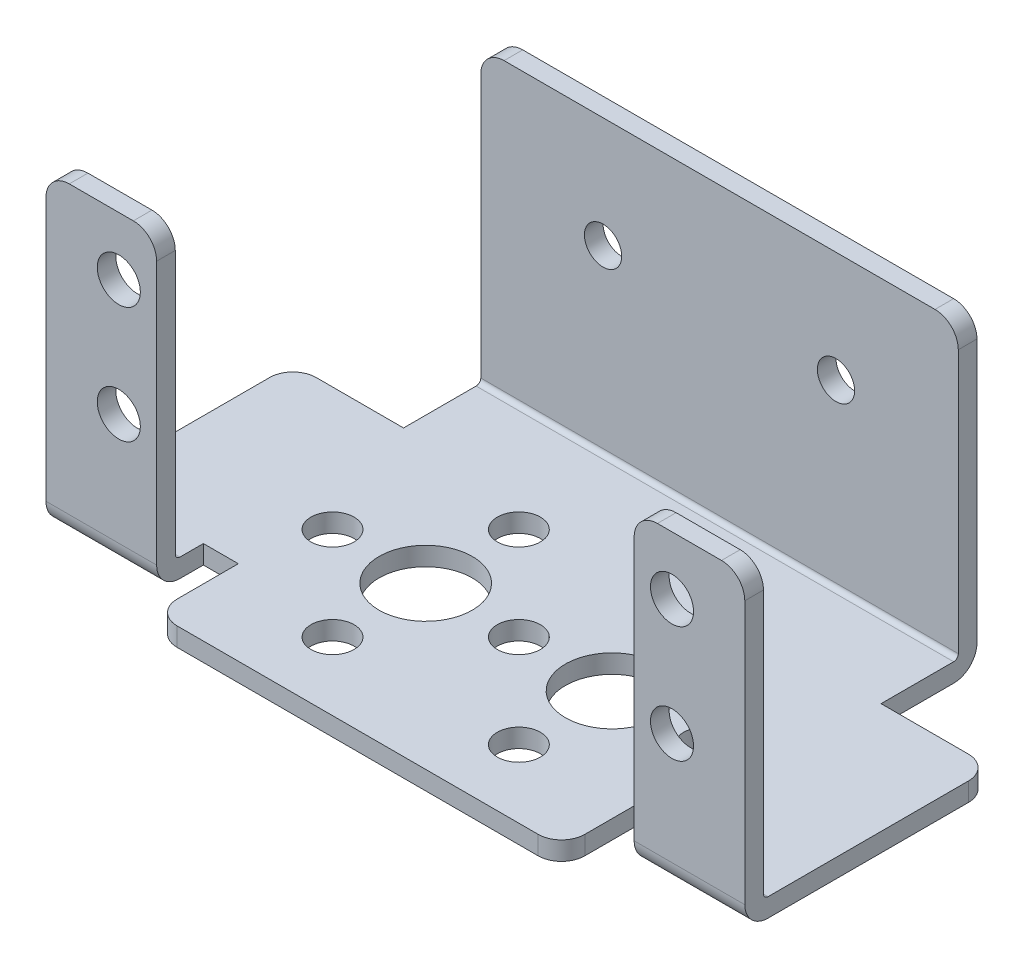
from build123d import *

# Parameters (mm, degrees)
EXTRUDE1_DEPTH             = 1.6
SKETCH2_W                  = 9.5
SKETCH2_H                  = 1.6
SKETCH2_W_2                = 41
EXTRUDE2_DEPTH             = 25
FILLET2_R                  = 0.4
FILLET3_R                  = 2
F_3_7_3_7_DIAMETER_HOLE1_D = 3.7
SKETCH4_R                  = 1.6
CUT_EXTRUDE2_DEPTH         = 2.6
SKETCH5_R                  = 4
CUT_EXTRUDE3_DEPTH         = 2.6
SKETCH5_3_R                = 1.85
CUT_EXTRUDE4_DEPTH         = 2.6
CIRPATTERN1_COUNT          = 4
SKETCH5_4_R                = 1.85
CUT_EXTRUDE5_DEPTH         = 10
CIRPATTERN2_COUNT          = 4


with BuildPart() as part:
    # Sketch1 → Extrude1 (new body)
    with BuildSketch(Plane(origin=(0, 0, 0), x_dir=(1, 0, 0), z_dir=(0, 1, 0))):
        Polygon((-30, -10.6), (-30, 10.6), (-20.5, 10.6), (-20.5, 18.83069384), (20.5, 18.83069384), (20.5, 10.6), (30, 10.6), (30, -10.6), (20.5, -10.6), (20.5, -6.588025881), (17.5, -6.588025881), (17.5, -13.838875216), (-17.5, -13.838875216), (-17.5, -6.588025881), (-20.5, -6.588025881), (-20.5, -10.6), align=None)
    extrude(amount=EXTRUDE1_DEPTH)

    # Sketch2 → Extrude2 (add)
    with BuildSketch(Plane(origin=(0, 1.6, 0), x_dir=(1, 0, 0), z_dir=(0, 1, 0))):
        with Locations((-25.25, -9.8)):
            Rectangle(SKETCH2_W, SKETCH2_H)
        with Locations((25.25, -9.8)):
            Rectangle(SKETCH2_W, SKETCH2_H)
        with Locations((0, 18.03069384)):
            Rectangle(SKETCH2_W_2, SKETCH2_H)
    extrude(amount=EXTRUDE2_DEPTH)

    # Fillet2
    fillet2_edges = [part.edges().sort_by_distance(p)[0] for p in [
        (-25.25, 1.6, 9),
        (25.25, 1.6, 9),
        (0, 1.6, -17.23069384),
    ]]
    fillet(fillet2_edges, radius=FILLET2_R)

    # Fillet3
    fillet3_edges = [part.edges().sort_by_distance(p)[0] for p in [
        (-30, 0.8, -10.6),
        (-17.5, 0.8, 13.838875216),
        (30, 0.8, -10.6),
        (20.5, 26.6, 9.8),
        (30, 26.6, 9.8),
        (20.5, 26.6, -18.03069384),
        (-20.5, 26.6, -18.03069384),
        (-30, 26.6, 9.8),
        (-20.5, 26.6, 9.8),
        (-25.25, 0, 10.6),
        (25.25, 0, 10.6),
        (0, 0, -18.83069384),
        (17.5, 0.8, 13.838875216),
    ]]
    fillet(fillet3_edges, radius=FILLET3_R)

    # 3.7 _3.7_ Diameter Hole1 (through all)
    with Locations(Plane.XY.offset(10.6)):
        with Locations((-23.75, 21.6), (-23.75, 11.6), (23.75, 11.6), (23.75, 21.6)):
            Hole(F_3_7_3_7_DIAMETER_HOLE1_D / 2)

    # Sketch4 → Cut-Extrude2 (cut, through all)
    with BuildSketch(Plane.XY.offset(-17.23069384)):
        with Locations((10, 17.09445923)):
            Circle(SKETCH4_R)
        with Locations((-10, 17.09445923)):
            Circle(SKETCH4_R)
    extrude(amount=-CUT_EXTRUDE2_DEPTH, mode=Mode.SUBTRACT)

    # Sketch5 → Cut-Extrude3 (cut, through all)
    with BuildSketch(Plane(origin=(0, 1.6, 0), x_dir=(1, 0, 0), z_dir=(0, 1, 0))):
        with Locations((8, 0)):
            Circle(SKETCH5_R)
        with Locations((-8, 0)):
            Circle(SKETCH5_R)
    extrude(amount=-CUT_EXTRUDE3_DEPTH, mode=Mode.SUBTRACT)

    # Sketch5_3 → Cut-Extrude4 (cut, through all)
    with BuildSketch(Plane(origin=(0, 1.6, 0), x_dir=(1, 0, 0), z_dir=(0, 1, 0))):
        with Locations((8, 8)):
            Circle(SKETCH5_3_R)
    cut_extrude4 = extrude(amount=-CUT_EXTRUDE4_DEPTH, mode=Mode.SUBTRACT)

    # CirPattern1: Cut-Extrude4 ×4 about axis
    cirpattern1_axis = Axis((8, 0, 0), (0, 1, 0))
    for i in range(1, CIRPATTERN1_COUNT):
        add(cut_extrude4.rotate(cirpattern1_axis, i * 360 / CIRPATTERN1_COUNT), mode=Mode.SUBTRACT)

    # Sketch5_4 → Cut-Extrude5 (cut)
    with BuildSketch(Plane(origin=(0, 1.6, 0), x_dir=(1, 0, 0), z_dir=(0, 1, 0))):
        with Locations((-8, 8)):
            Circle(SKETCH5_4_R)
    cut_extrude5 = extrude(amount=-CUT_EXTRUDE5_DEPTH, mode=Mode.SUBTRACT)

    # CirPattern2: Cut-Extrude5 ×4 about axis
    cirpattern2_axis = Axis((-8, 0, 0), (0, 1, 0))
    for i in range(1, CIRPATTERN2_COUNT):
        add(cut_extrude5.rotate(cirpattern2_axis, i * 360 / CIRPATTERN2_COUNT), mode=Mode.SUBTRACT)


solid = part.part
